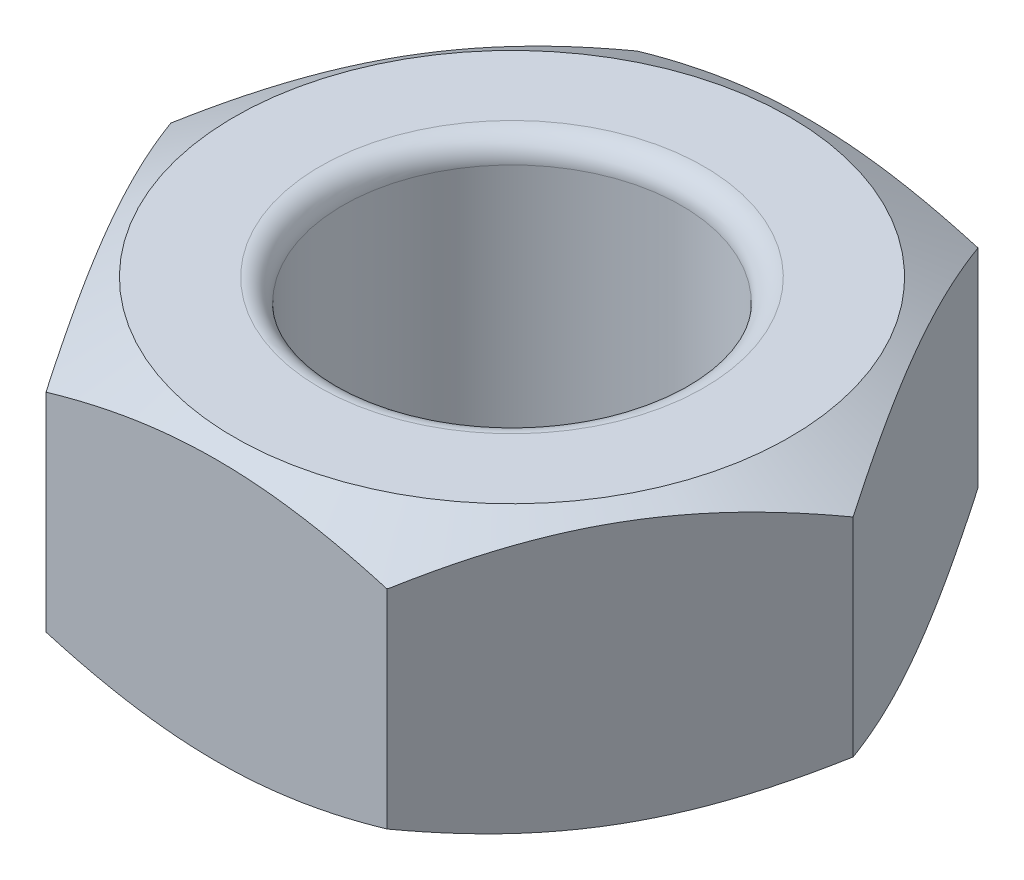
from build123d import *

# Parameters (mm, degrees)
SKETCH1_R           = 3
BOSS_EXTRUDE1_DEPTH = 5
FILLET1_R           = 0.4


with BuildPart() as part:
    # Sketch1 → Boss-Extrude1 (new body)
    with BuildSketch(Plane(origin=(0, 0, 0), x_dir=(1, 0, 0), z_dir=(0, 1, 0))):
        Polygon((6.0450921, 0), (3.02254605, 5.235203327), (-3.02254605, 5.235203327), (-6.0450921, 0), (-3.02254605, -5.235203327), (3.02254605, -5.235203327), align=None)
        Circle(SKETCH1_R, mode=Mode.SUBTRACT)
    extrude(amount=BOSS_EXTRUDE1_DEPTH)

    # Sketch2 → Cut-Revolve1 (revolve, cut)
    with BuildSketch(Plane(origin=(0, 0, 0), x_dir=(-0.5, 0, -0.866025404), z_dir=(0.866025404, 0, -0.5))):
        Polygon((-6.389496142, 4.34485452), (-6.038887138, 4.34485452), (-4.919612053, 5), (-6.274952166, 5.0992455), align=None)
    cut_revolve1 = revolve(axis=Axis((0, 0, 0), (0, 1, 0)), mode=Mode.SUBTRACT)

    # Mirror1: Cut-Revolve1 across plane
    add(cut_revolve1.mirror(Plane.ZX.offset(2.5)), mode=Mode.SUBTRACT)

    # Fillet1
    fillet1_edges = [part.edges().sort_by_distance(p)[0] for p in [
        (-3, 0, 0),
        (-3, 5, 0),
    ]]
    fillet(fillet1_edges, radius=FILLET1_R)


solid = part.part
